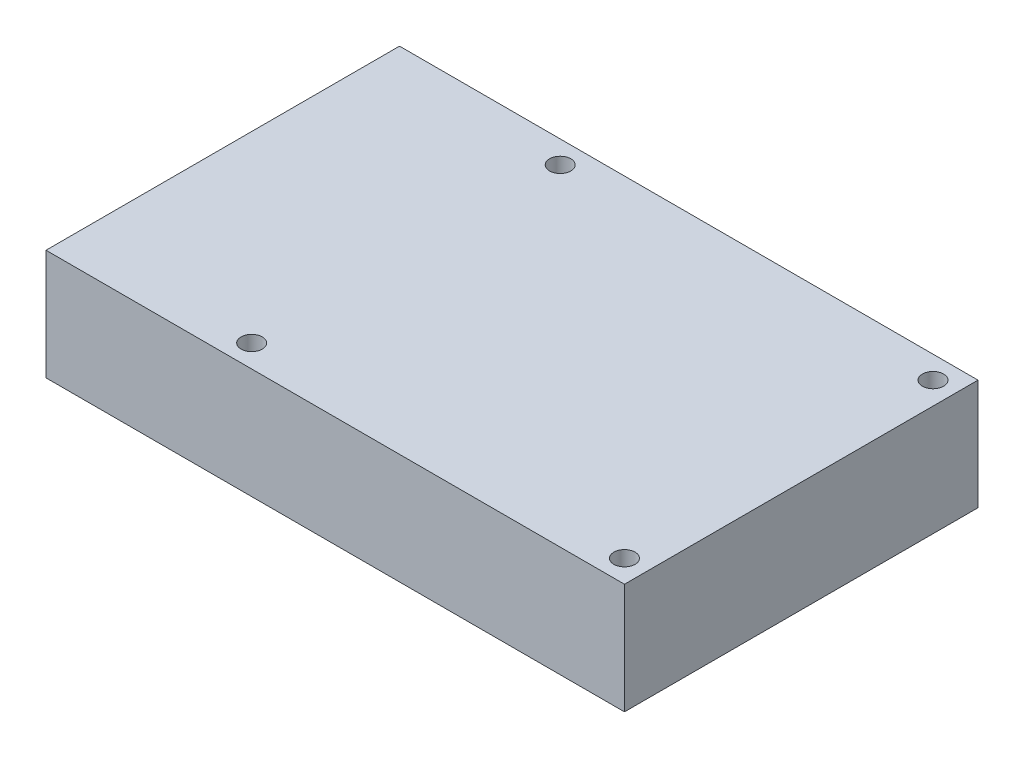
from build123d import *

# Parameters (mm, degrees)
SKETCH1_W           = 90
SKETCH1_H           = 55
BOSS_EXTRUDE2_DEPTH = 17.2
SKETCH2_R           = 1.65
CUT_EXTRUDE1_DEPTH  = 18.2


with BuildPart() as part:
    # Sketch1 → Boss-Extrude2 (new body)
    with BuildSketch(Plane(origin=(0, 0, 0), x_dir=(1, 0, 0), z_dir=(0, 1, 0))):
        Rectangle(SKETCH1_W, SKETCH1_H)
    extrude(amount=BOSS_EXTRUDE2_DEPTH)

    # Sketch2 → Cut-Extrude1 (cut, through all)
    with BuildSketch(Plane(origin=(0, 17.2, 0), x_dir=(1, 0, 0), z_dir=(0, 1, 0))):
        with Locations((41.5, 24)):
            Circle(SKETCH2_R)
        with Locations((41.5, -24)):
            Circle(SKETCH2_R)
        with Locations((-16.5, -24)):
            Circle(SKETCH2_R)
        with Locations((-16.5, 24)):
            Circle(SKETCH2_R)
    extrude(amount=-CUT_EXTRUDE1_DEPTH, mode=Mode.SUBTRACT)


solid = part.part
